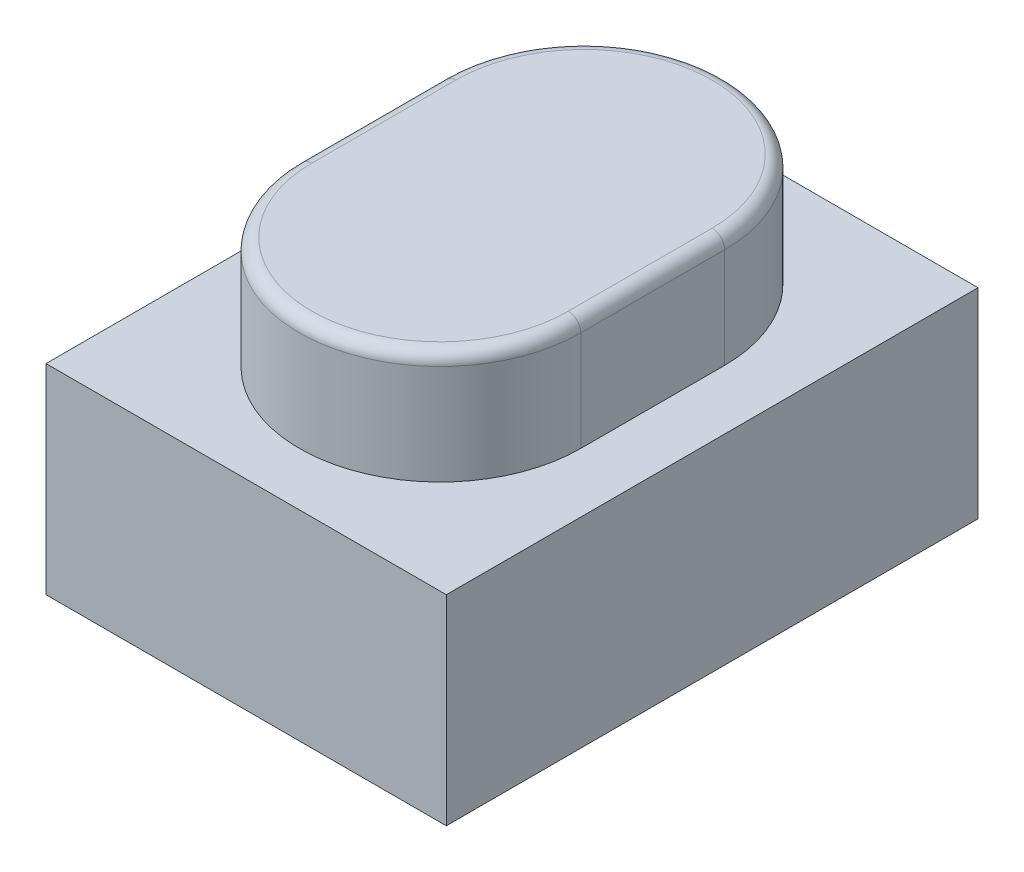
from build123d import *

# Parameters (mm, degrees)
BASES_W      = 3.2
BASES_H      = 4.25
BASE_DEPTH   = 1.6
BUTTON_DEPTH = 0.9
BF_R         = 0.1


with BuildPart() as part:
    # BaseS → Base (new body)
    with BuildSketch(Plane(origin=(0, 0, 0), x_dir=(1, 0, 0), z_dir=(0, 1, 0))):
        Rectangle(BASES_W, BASES_H)
    extrude(amount=BASE_DEPTH)

    # ButtonS → Button (add)
    with BuildSketch(Plane(origin=(0, 1.6, 0), x_dir=(1, 0, 0), z_dir=(0, 1, 0))):
        with BuildLine():
            Line((1.125, 0.575), (1.125, -0.575))
            ThreePointArc((1.125, -0.575), (0, -1.7), (-1.125, -0.575))
            Line((-1.125, -0.575), (-1.125, 0.575))
            ThreePointArc((-1.125, 0.575), (0, 1.7), (1.125, 0.575))
        make_face()
    extrude(amount=BUTTON_DEPTH)

    # BF
    bf_edges = [part.edges().sort_by_distance(p)[0] for p in [
        (0, 2.5, -1.7),
        (-1.125, 2.5, 0),
        (0, 2.5, 1.7),
        (1.125, 2.5, 0),
    ]]
    fillet(bf_edges, radius=BF_R)


solid = part.part
